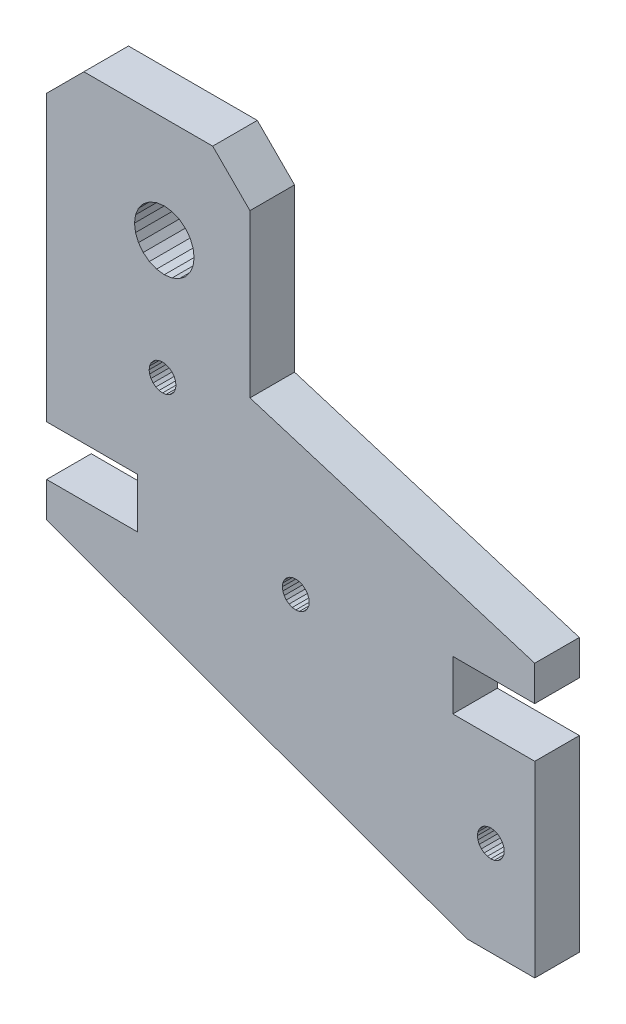
from build123d import *

# Parameters (mm, degrees)
BOSS_EXTRUDE1_DEPTH = 6


with BuildPart() as part:
    # Sketch1 → Boss-Extrude1 (new body)
    with BuildSketch(Plane.XY):
        Polygon((349.805861239, 49.832080259), (349.805861239, 56.546676312), (337.582956824, 56.546676312), (337.582956824, 94.832680829), (342.594184557, 99.843908562), (359.928534592, 99.843908562), (364.939762315, 94.832680839), (364.939762315, 73.014449736), (403.254521851, 61.257454897), (403.254521851, 56.546676274), (392.232066466, 56.546676274), (392.232066466, 49.832080221), (403.26125874, 49.832080221), (403.26125874, 24.580912459), (394.140824266, 24.580912459), (337.582956824, 45.121301639), (337.582956824, 49.832080259), align=None)
        Polygon((396.07235895, 38.585081223), (396.445988279, 38.87177709), (396.881088847, 39.052001647), (397.348009271, 39.113472887), (397.814929694, 39.052001647), (398.250030262, 38.87177709), (398.623659591, 38.585081223), (398.910355458, 38.211451895), (399.090580014, 37.776351326), (399.152051254, 37.309430903), (399.090580014, 36.842510479), (398.910355458, 36.407409911), (398.623659591, 36.033780583), (398.250030262, 35.747084715), (397.814929694, 35.566860159), (397.348009271, 35.505388919), (396.881088847, 35.566860159), (396.445988279, 35.747084715), (396.07235895, 36.033780583), (395.785663083, 36.407409911), (395.605438527, 36.842510479), (395.543967287, 37.309430903), (395.605438527, 37.776351326), (395.785663083, 38.211451895), align=None, mode=Mode.SUBTRACT)
        Polygon((351.375405933, 69.514088989), (351.436877173, 69.047168565), (351.617101729, 68.612067997), (351.903797596, 68.238438669), (352.277426924, 67.951742801), (352.712527493, 67.771518245), (353.179447916, 67.710047005), (353.64636834, 67.771518245), (354.081468908, 67.951742801), (354.455098237, 68.238438669), (354.741794104, 68.612067997), (354.92201866, 69.047168565), (354.9834899, 69.514088989), (354.92201866, 69.981009412), (354.741794104, 70.416109981), (354.455098237, 70.789739309), (354.081468908, 71.076435176), (353.64636834, 71.256659733), (353.179447916, 71.318130973), (352.712527493, 71.256659733), (352.277426924, 71.076435176), (351.903797596, 70.789739309), (351.617101729, 70.416109981), (351.436877173, 69.981009412), align=None, mode=Mode.SUBTRACT)
        Polygon((372.381509854, 54.465028594), (372.007880526, 54.751724461), (371.572779958, 54.931949018), (371.105859534, 54.993420258), (370.638939111, 54.931949018), (370.203838542, 54.751724461), (369.830209214, 54.465028594), (369.543513347, 54.091399266), (369.36328879, 53.656298697), (369.30181755, 53.189378274), (369.36328879, 52.72245785), (369.543513347, 52.287357282), (369.830209214, 51.913727954), (370.203838542, 51.627032087), (370.638939111, 51.44680753), (371.105859534, 51.38533629), (371.572779958, 51.44680753), (372.007880526, 51.627032087), (372.381509854, 51.913727954), (372.668205722, 52.287357282), (372.848430278, 52.72245785), (372.909901518, 53.189378274), (372.848430278, 53.656298697), (372.668205722, 54.091399266), align=None, mode=Mode.SUBTRACT)
        Polygon((350.579160049, 82.777243303), (351.409447446, 82.140141376), (352.376337597, 81.739642362), (353.413938539, 81.603039606), (354.45153948, 81.739642362), (355.418429632, 82.140141376), (356.248717028, 82.777243303), (356.885818955, 83.607530699), (357.286317969, 84.574420851), (357.422920725, 85.612021792), (357.286317969, 86.649622733), (356.885818955, 87.616512885), (356.248717028, 88.446800282), (355.418429632, 89.083902209), (354.45153948, 89.484401223), (353.413938539, 89.621003978), (352.376337597, 89.484401223), (351.409447446, 89.083902209), (350.579160049, 88.446800282), (349.942058122, 87.616512885), (349.541559108, 86.649622733), (349.404956353, 85.612021792), (349.541559108, 84.574420851), (349.942058122, 83.607530699), align=None, mode=Mode.SUBTRACT)
    extrude(amount=BOSS_EXTRUDE1_DEPTH)


solid = part.part
